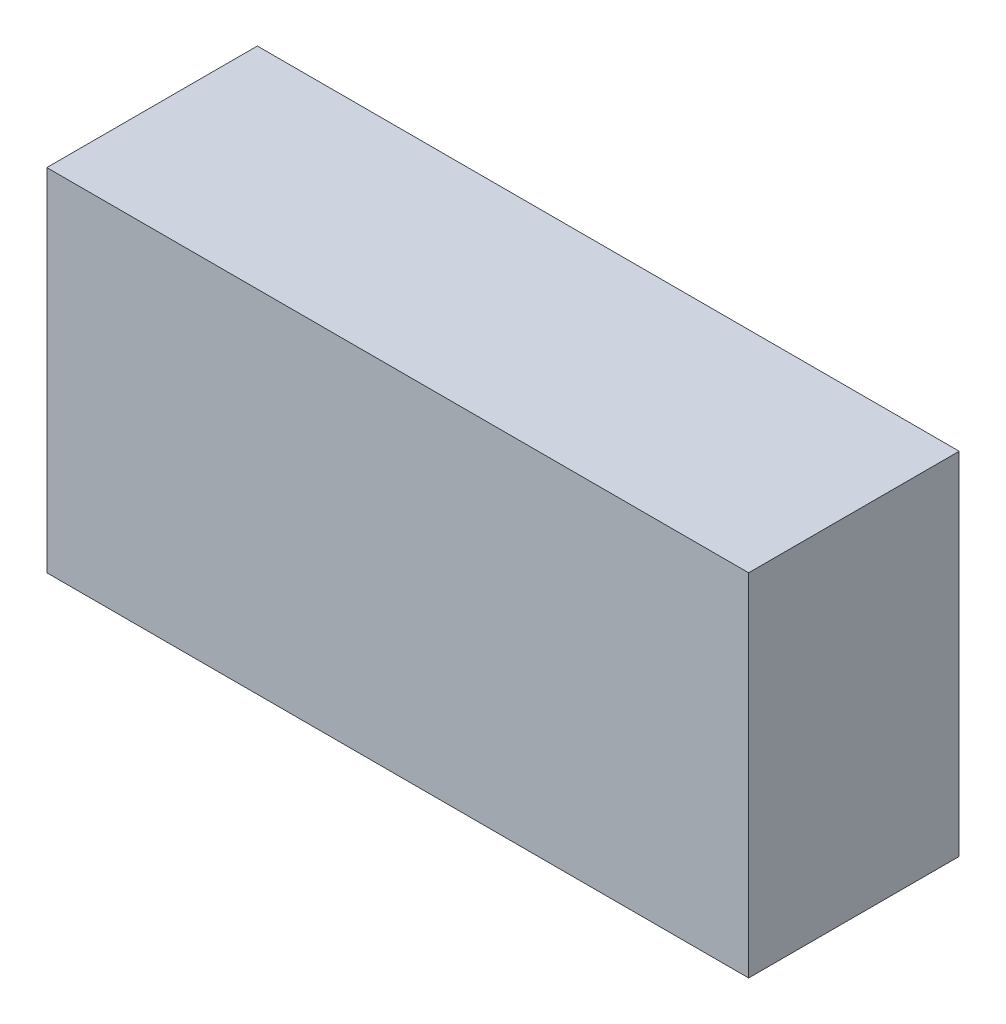
from build123d import *

# Parameters (mm, degrees)
ESBO_O1_W                = 10
ESBO_O1_H                = 5
RESSALTO_EXTRUS_O1_DEPTH = 3


with BuildPart() as part:
    # Esboço1 → Ressalto-extrusão1 (new body)
    with BuildSketch(Plane.XY):
        Rectangle(ESBO_O1_W, ESBO_O1_H)
    extrude(amount=RESSALTO_EXTRUS_O1_DEPTH)


solid = part.part
